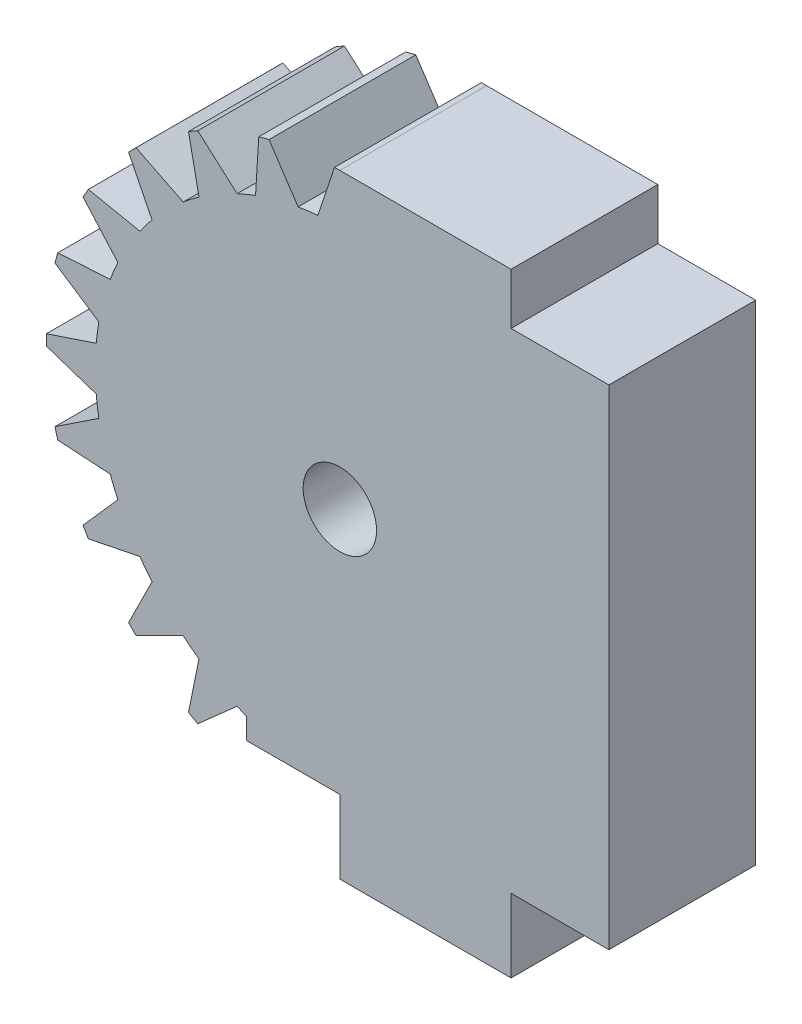
from build123d import *

# Parameters (mm, degrees)
SKETCH1_R           = 10
BOSS_EXTRUDE1_DEPTH = 6
BOSS_EXTRUDE2_DEPTH = 6
CIRPATTERN1_COUNT   = 24
SKETCH3_R           = 12.65
SKETCH3_R_2         = 12
CUT_EXTRUDE1_DEPTH  = 6
CUT_EXTRUDE2_DEPTH  = 6
SKETCH5_R           = 1.5
CUT_EXTRUDE3_DEPTH  = 6
BOSS_EXTRUDE3_DEPTH = 6


with BuildPart() as part:
    # Sketch1 → Boss-Extrude1 (new body)
    with BuildSketch(Plane.XY):
        Circle(SKETCH1_R)
    extrude(amount=BOSS_EXTRUDE1_DEPTH)

    # Sketch2 → Boss-Extrude2 (add)
    with BuildSketch(Plane.XY):
        with BuildLine():
            Line((0, 12.65), (-0.9, 9.959417654))
            ThreePointArc((-0.9, 9.959417654), (0, 10), (0.9, 9.959417654))
            Line((0.9, 9.959417654), (0, 12.65))
        make_face()
    boss_extrude2 = extrude(amount=BOSS_EXTRUDE2_DEPTH)

    # CirPattern1: Boss-Extrude2 ×24 about axis
    cirpattern1_axis = Axis((0, 0, 0), (0, 0, 1))
    for i in range(1, CIRPATTERN1_COUNT):
        add(boss_extrude2.rotate(cirpattern1_axis, i * 360 / CIRPATTERN1_COUNT))

    # Sketch3 → Cut-Extrude1 (cut)
    with BuildSketch(Plane.XY):
        Circle(SKETCH3_R)
        Circle(SKETCH3_R_2, mode=Mode.SUBTRACT)
    extrude(amount=CUT_EXTRUDE1_DEPTH, mode=Mode.SUBTRACT)

    # Sketch4 → Cut-Extrude2 (cut)
    with BuildSketch(Plane.XY):
        with BuildLine():
            Line((0, 0), (0, 12))
            ThreePointArc((0, 12), (11.769423365, -2.341083864), (-4.592201188, -11.08655439))
            Line((-4.592201188, -11.08655439), (-3.826834324, -9.238795325))
            Line((-3.826834324, -9.238795325), (0, 0))
        make_face()
    extrude(amount=CUT_EXTRUDE2_DEPTH, mode=Mode.SUBTRACT)

    # Sketch5 → Cut-Extrude3 (cut)
    with BuildSketch(Plane.XY):
        Circle(SKETCH5_R)
    extrude(amount=CUT_EXTRUDE3_DEPTH, mode=Mode.SUBTRACT)

    # Sketch6 → Boss-Extrude3 (add)
    with BuildSketch(Plane.XY):
        with BuildLine():
            Line((0, 1.5), (0, 12))
            Line((0, 12), (7, 12))
            Line((7, 12), (7, 9.904493766))
            Line((7, 9.904493766), (11, 9.904493766))
            Line((11, 9.904493766), (11, -10.095506234))
            Line((11, -10.095506234), (7, -10.095506234))
            Line((7, -10.095506234), (7, -13.095506234))
            Line((7, -13.095506234), (0, -13.095506234))
            Line((0, -13.095506234), (0, -10.095506234))
            Line((0, -10.095506234), (-3.826834324, -10.095506234))
            Line((-3.826834324, -10.095506234), (-3.826834324, -9.238795325))
            Line((-3.826834324, -9.238795325), (-0.574025149, -1.385819299))
            ThreePointArc((-0.574025149, -1.385819299), (1.471177921, -0.292635483), (0, 1.5))
        make_face()
    extrude(amount=BOSS_EXTRUDE3_DEPTH)


solid = part.part
